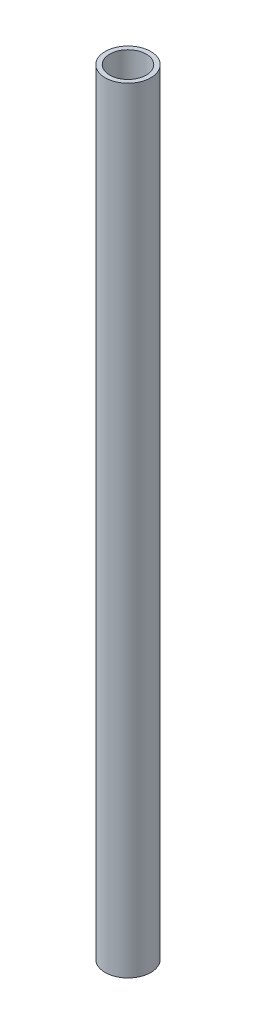
from build123d import *

# Parameters (mm, degrees)
SKETCH1_R           = 5
SKETCH1_R_2         = 4
BOSS_EXTRUDE1_DEPTH = 170


with BuildPart() as part:
    # Sketch1 → Boss-Extrude1 (new body)
    with BuildSketch(Plane(origin=(0, 0, 0), x_dir=(1, 0, 0), z_dir=(0, 1, 0))):
        Circle(SKETCH1_R)
        Circle(SKETCH1_R_2, mode=Mode.SUBTRACT)
    extrude(amount=BOSS_EXTRUDE1_DEPTH)


solid = part.part
